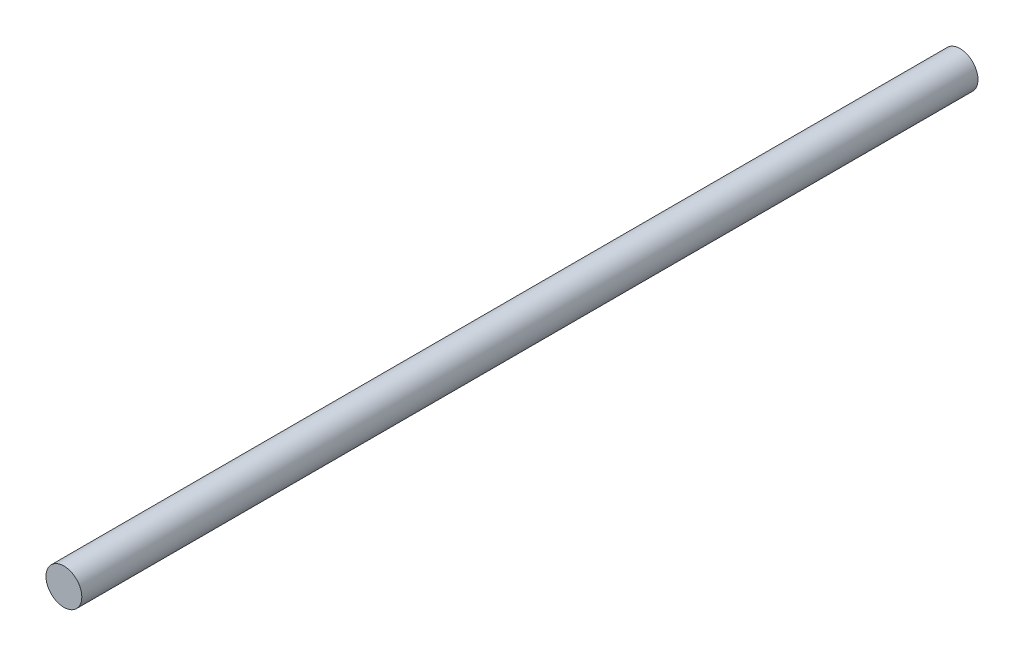
from build123d import *

# Parameters (mm, degrees)
ESBO_O1_R                = 10
RESSALTO_EXTRUS_O1_DEPTH = 500


with BuildPart() as part:
    # Esboço1 → Ressalto-extrusão1 (new body)
    with BuildSketch(Plane.XY):
        Circle(ESBO_O1_R)
    extrude(amount=RESSALTO_EXTRUS_O1_DEPTH)


solid = part.part
